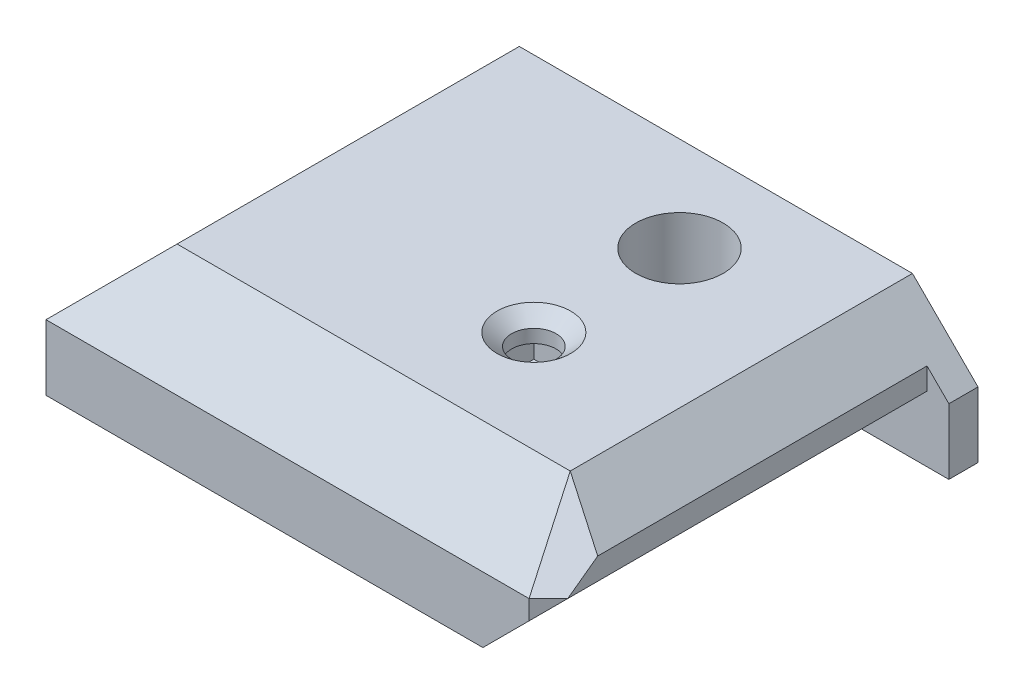
from build123d import *

# Parameters (mm, degrees)
SKETCH1_W                                         = 36
SKETCH1_H                                         = 9
BOSS_EXTRUDE1_DEPTH                               = 28
CUT_EXTRUDE1_DEPTH                                = 28
CUT_EXTRUDE2_DEPTH                                = 36
SKETCH5_W                                         = 11.440376565
SKETCH5_H                                         = 15.618965423
CUT_EXTRUDE4_DEPTH                                = 2
CUT_EXTRUDE5_DEPTH                                = 2
CUT_EXTRUDE5_DEPTH_BACK                           = 2
CUT_EXTRUDE6_DEPTH                                = 26
CUT_EXTRUDE7_DEPTH                                = 26
SKETCH10_R                                        = 3
CUT_EXTRUDE8_DEPTH                                = 7
SKETCH11_R                                        = 1.5
CUT_EXTRUDE9_DEPTH                                = 2
SKETCH12_R                                        = 1.5
CUT_EXTRUDE10_DEPTH                               = 9
CSK_FOR_3_FLAT_HEAD_MACHINE_SCREW_100_D           = 3.048
CSK_FOR_3_FLAT_HEAD_MACHINE_SCREW_100_DEPTH       = 9
CSK_FOR_3_FLAT_HEAD_MACHINE_SCREW_100_CSINK_D     = 5.0546
CSK_FOR_3_FLAT_HEAD_MACHINE_SCREW_100_CSINK_ANGLE = 100
SKETCH15_W                                        = 5.3
SKETCH15_H                                        = 5.3
CUT_EXTRUDE11_DEPTH                               = 2.5


with BuildPart() as part:
    # Sketch1 → Boss-Extrude1 (new body)
    with BuildSketch(Plane.XY):
        with Locations((18, 4.5)):
            Rectangle(SKETCH1_W, SKETCH1_H)
    extrude(amount=BOSS_EXTRUDE1_DEPTH)

    # Sketch2 → Cut-Extrude1 (cut)
    with BuildSketch(Plane.XY):
        Polygon((0, 4.5), (4.5, 9), (0, 9), align=None)
        Polygon((36, 4.5), (31.5, 9), (36, 9), align=None)
    extrude(amount=CUT_EXTRUDE1_DEPTH, mode=Mode.SUBTRACT)

    # Sketch3 → Cut-Extrude2 (cut)
    with BuildSketch(Plane(origin=(0, 0, 0), x_dir=(0, 0, -1), z_dir=(1, 0, 0))):
        Polygon((-28, 4.5), (-23.5, 9), (-28, 9), align=None)
    extrude(amount=CUT_EXTRUDE2_DEPTH, mode=Mode.SUBTRACT)

    # Sketch5 → Cut-Extrude4 (cut)
    with BuildSketch(Plane(origin=(32, 0, 32), x_dir=(0, 1, 0), z_dir=(0.707106781, 0, 0.707106781))):
        with Locations((5.720188283, -5.935696583)):
            Rectangle(SKETCH5_W, SKETCH5_H)
    extrude(amount=-CUT_EXTRUDE4_DEPTH, mode=Mode.SUBTRACT)

    # Sketch6 → Cut-Extrude5 (cut, two sides)
    with BuildSketch(Plane(origin=(4, 0, -4), x_dir=(0.577350269, -0.577350269, 0.577350269), z_dir=(-0.707106781, 0, 0.707106781))) as cut_extrude5_sk:
        Polygon((26.558112383, 29.802125204), (32.719347855, 28.647424665), (30.19862658, 32.212262879), align=None)
    extrude(amount=CUT_EXTRUDE5_DEPTH, mode=Mode.SUBTRACT)
    extrude(cut_extrude5_sk.sketch, amount=-CUT_EXTRUDE5_DEPTH_BACK, mode=Mode.SUBTRACT)

    # Sketch7 → Cut-Extrude6 (cut)
    with BuildSketch(Plane.XY):
        Polygon((5, 0), (5, 3), (5.707106781, 3.707106781), (13.104524105, 3.707106781), (13.811630886, 3), (13.811630886, 0), align=None)
    extrude(amount=CUT_EXTRUDE6_DEPTH, mode=Mode.SUBTRACT)

    # Sketch8 → Cut-Extrude7 (cut)
    with BuildSketch(Plane.XY.offset(28)):
        Polygon((36, 0), (30, 0), (34.5, 4.5), (34.5, 6), (36, 6), align=None)
    extrude(amount=-CUT_EXTRUDE7_DEPTH, mode=Mode.SUBTRACT)

    # Sketch10 → Cut-Extrude8 (cut)
    with BuildSketch(Plane(origin=(0, 9, 0), x_dir=(1, 0, 0), z_dir=(0, 1, 0))):
        with Locations((22, -6.5)):
            Circle(SKETCH10_R)
    extrude(amount=-CUT_EXTRUDE8_DEPTH, mode=Mode.SUBTRACT)

    # Sketch11 → Cut-Extrude9 (cut)
    with BuildSketch(Plane(origin=(0, 2, 0), x_dir=(1, 0, 0), z_dir=(0, 1, 0))):
        with Locations((22, -6.5)):
            Circle(SKETCH11_R)
    extrude(amount=-CUT_EXTRUDE9_DEPTH, mode=Mode.SUBTRACT)

    # Sketch12 → Cut-Extrude10 (cut)
    with BuildSketch(Plane(origin=(0, 0, 0), x_dir=(1, 0, 0), z_dir=(0, 1, 0))):
        with Locations((22, -16.5)):
            Circle(SKETCH12_R)
    extrude(amount=CUT_EXTRUDE10_DEPTH, mode=Mode.SUBTRACT)

    # CSK for _3 Flat Head Machine Screw _100
    with Locations(Plane(origin=(22, 9, 16.5), x_dir=(0, 0, 1), z_dir=(0, 1, 0))):
        with Locations((0, 0)):
            CounterSinkHole(CSK_FOR_3_FLAT_HEAD_MACHINE_SCREW_100_D / 2, CSK_FOR_3_FLAT_HEAD_MACHINE_SCREW_100_CSINK_D / 2, depth=CSK_FOR_3_FLAT_HEAD_MACHINE_SCREW_100_DEPTH, counter_sink_angle=CSK_FOR_3_FLAT_HEAD_MACHINE_SCREW_100_CSINK_ANGLE)

    # Sketch15 → Cut-Extrude11 (cut)
    with BuildSketch(Plane(origin=(0, 4.75, 0), x_dir=(1, 0, 0), z_dir=(0, 1, 0))):
        with Locations((22, -16.5)):
            Rectangle(SKETCH15_W, SKETCH15_H)
    extrude(amount=CUT_EXTRUDE11_DEPTH, mode=Mode.SUBTRACT)


solid = part.part
